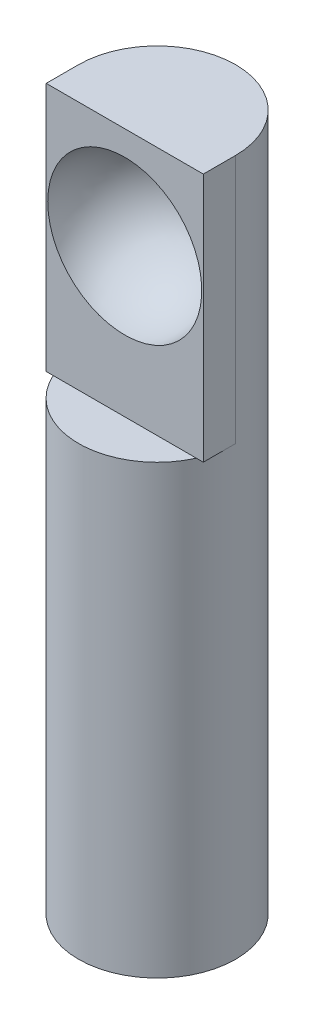
from build123d import *

# Parameters (mm, degrees)
SKETCH1_W           = 5.1
SKETCH1_H           = 22.6
BOSS_EXTRUDE1_DEPTH = 2.55
SKETCH3_W           = 5.1
SKETCH3_H           = 8.1
BOSS_EXTRUDE2_DEPTH = 1
CUT_EXTRUDE1_DEPTH  = 14.5
SKETCH5_W           = 5.1
SKETCH5_H           = 1.5
CUT_EXTRUDE2_DEPTH  = 8.1
CUT_EXTRUDE3_DEPTH  = 16.144470938


with BuildPart() as part:
    # Sketch1 → Boss-Extrude1 (new, symmetric)
    with BuildSketch(Plane.XY):
        Rectangle(SKETCH1_W, SKETCH1_H)
    extrude(amount=BOSS_EXTRUDE1_DEPTH, both=True)

    # Sketch3 → Boss-Extrude2 (add)
    with BuildSketch(Plane(origin=(0, 0, -2.55), x_dir=(-1, 0, 0), z_dir=(0, 0, -1))):
        with Locations((0, 7.25)):
            Rectangle(SKETCH3_W, SKETCH3_H)
    extrude(amount=BOSS_EXTRUDE2_DEPTH)

    # Sketch4 → Cut-Extrude1 (cut)
    with BuildSketch(Plane.XZ.offset(11.3)):
        with BuildLine():
            Line((0, 2.55), (-2.55, 2.55))
            Line((-2.55, 2.55), (-2.55, 0))
            ThreePointArc((-2.55, 0), (-1.803122292, 1.803122292), (0, 2.55))
        make_face()
        with BuildLine():
            Line((2.55, 2.55), (0, 2.55))
            ThreePointArc((0, 2.55), (1.803122292, 1.803122292), (2.55, 0))
            Line((2.55, 0), (2.55, 2.55))
        make_face()
        with BuildLine():
            ThreePointArc((2.55, 0), (1.803122292, -1.803122292), (0, -2.55))
            Line((0, -2.55), (2.55, -2.55))
            Line((2.55, -2.55), (2.55, 0))
        make_face()
        with BuildLine():
            ThreePointArc((0, -2.55), (-1.803122292, -1.803122292), (-2.55, 0))
            Line((-2.55, 0), (-2.55, -2.55))
            Line((-2.55, -2.55), (0, -2.55))
        make_face()
    extrude(amount=-CUT_EXTRUDE1_DEPTH, mode=Mode.SUBTRACT)

    # Sketch5 → Cut-Extrude2 (cut)
    with BuildSketch(Plane(origin=(0, 11.3, 0), x_dir=(1, 0, 0), z_dir=(0, 1, 0))):
        with Locations((0, -1.8)):
            Rectangle(SKETCH5_W, SKETCH5_H)
    extrude(amount=-CUT_EXTRUDE2_DEPTH, mode=Mode.SUBTRACT)

    # Sketch6 → Cut-Revolve2 (revolve, cut)
    with BuildSketch(Plane.XY.offset(1.05)):
        with BuildLine():
            Line((-2.5, 8), (2.5, 8))
            ThreePointArc((2.5, 8), (0, 5.5), (-2.5, 8))
        make_face()
    revolve(axis=Axis((-2.5, 8, 1.05), (1, 0, 0)), mode=Mode.SUBTRACT)

    # Sketch7 → Cut-Extrude3 (cut, through all)
    with BuildSketch(Plane.XZ.offset(-3.2)):
        with BuildLine():
            Line((-2.55, -3.55), (2.55, -3.55))
            Line((2.55, -3.55), (2.55, 0))
            ThreePointArc((2.55, 0), (0, -2.55), (-2.55, 0))
            Line((-2.55, 0), (-2.55, -3.55))
        make_face()
    extrude(amount=-CUT_EXTRUDE3_DEPTH, mode=Mode.SUBTRACT)


solid = part.part
